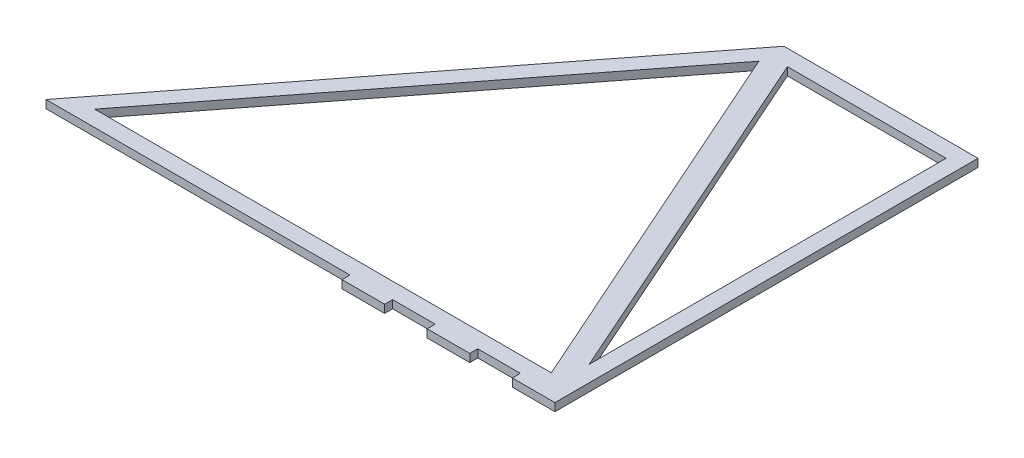
from build123d import *

# Parameters (mm, degrees)
BOSS_EXTRUDE1_DEPTH = 4.7625


with BuildPart() as part:
    # Sketch1 → Boss-Extrude1 (new body)
    with BuildSketch(Plane(origin=(0, 0, 0), x_dir=(1, 0, 0), z_dir=(0, 1, 0))):
        Polygon((-19.475189916, -9.525), (161.925, -9.525), (161.925, -14.2875), (187.325, -14.2875), (187.325, -9.525), (212.725, -9.525), (212.725, -14.2875), (238.125, -14.2875), (238.125, -9.525), (263.525, -9.525), (263.525, -14.2875), (288.925, -14.2875), (288.925, 238.125), (173.141476751, 238.125), align=None)
        Polygon((272.451083662, 0), (0, 0), (173.37796233, 222.914522996), align=None, mode=Mode.SUBTRACT)
        Polygon((184.748916338, 228.6), (279.4, 228.6), (279.4, 15.63506176), align=None, mode=Mode.SUBTRACT)
    extrude(amount=BOSS_EXTRUDE1_DEPTH)


solid = part.part
